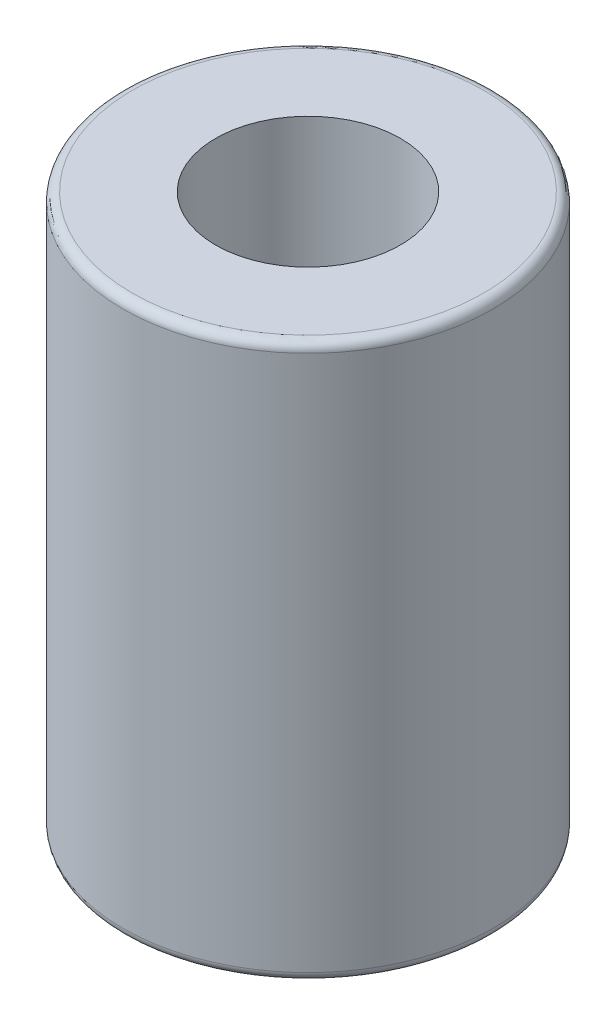
from build123d import *

# Parameters (mm, degrees)
SKETCH1_R           = 5
BOSS_EXTRUDE1_DEPTH = 15
SKETCH2_R           = 2.5
CUT_EXTRUDE1_DEPTH  = 15
FILLET1_R           = 0.25


with BuildPart() as part:
    # Sketch1 → Boss-Extrude1 (new body)
    with BuildSketch(Plane(origin=(0, 0, 0), x_dir=(1, 0, 0), z_dir=(0, 1, 0))):
        Circle(SKETCH1_R)
    extrude(amount=BOSS_EXTRUDE1_DEPTH)

    # Sketch2 → Cut-Extrude1 (cut)
    with BuildSketch(Plane(origin=(0, 15, 0), x_dir=(1, 0, 0), z_dir=(0, 1, 0))):
        Circle(SKETCH2_R)
    extrude(amount=-CUT_EXTRUDE1_DEPTH, mode=Mode.SUBTRACT)

    # Fillet1
    fillet1_edges = [part.edges().sort_by_distance(p)[0] for p in [
        (-5, 0, 0),
        (-5, 15, 0),
    ]]
    fillet(fillet1_edges, radius=FILLET1_R)


solid = part.part
